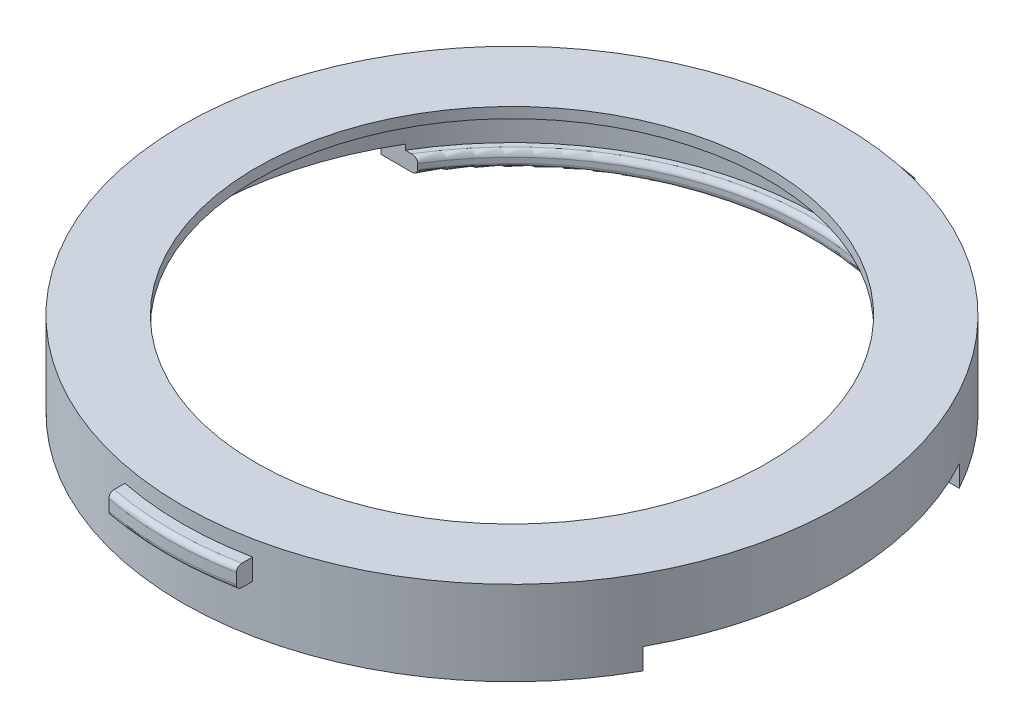
from build123d import *

# Parameters (mm, degrees)
SKETCH1_R                = 31.25
SKETCH1_R_2              = 29.25
BOSS_EXTRUDE2_DEPTH      = 8
SKETCH3_R                = 29.25
SKETCH3_R_2              = 28.25
BOSS_EXTRUDE3_DEPTH      = 1.5
FILLET1_R                = 0.5
SKETCH4_R                = 29.25
SKETCH4_R_2              = 24.25
BOSS_EXTRUDE4_DEPTH      = 1
CUT_EXTRUDE3_START       = 5
SKETCH5_W                = 70
SKETCH5_H                = 30
CUT_EXTRUDE3_DEPTH       = 2
BOSS_EXTRUDE5_DEPTH      = 1
BOSS_EXTRUDE5_DEPTH_BACK = 1
FILLET3_R                = 0.5


with BuildPart() as part:
    # Sketch1 → Boss-Extrude2 (new body)
    with BuildSketch(Plane(origin=(0, 0, 0), x_dir=(1, 0, 0), z_dir=(0, 1, 0))):
        Circle(SKETCH1_R)
        Circle(SKETCH1_R_2, mode=Mode.SUBTRACT)
    extrude(amount=BOSS_EXTRUDE2_DEPTH)

    # Sketch3 → Boss-Extrude3 (add)
    with BuildSketch(Plane(origin=(0, 1.5, 0), x_dir=(1, 0, 0), z_dir=(0, 1, 0))):
        Circle(SKETCH3_R)
        Circle(SKETCH3_R_2, mode=Mode.SUBTRACT)
    extrude(amount=-BOSS_EXTRUDE3_DEPTH)

    # Fillet1
    fillet1_edges = [part.edges().sort_by_distance(p)[0] for p in [
        (-28.25, 0, 0),
        (-28.25, 1.5, 0),
    ]]
    fillet(fillet1_edges, radius=FILLET1_R)

    # Sketch4 → Boss-Extrude4 (add)
    with BuildSketch(Plane(origin=(0, 8, 0), x_dir=(1, 0, 0), z_dir=(0, 1, 0))):
        Circle(SKETCH4_R)
        Circle(SKETCH4_R_2, mode=Mode.SUBTRACT)
    extrude(amount=-BOSS_EXTRUDE4_DEPTH)

    # Sketch5 → Cut-Extrude3 (cut)
    with BuildSketch(Plane.XZ.offset(-7).offset(CUT_EXTRUDE3_START)):
        Rectangle(SKETCH5_W, SKETCH5_H)
    extrude(amount=CUT_EXTRUDE3_DEPTH, mode=Mode.SUBTRACT)

    # Sketch6 → Boss-Extrude5 (add, two sides)
    with BuildSketch(Plane(origin=(0, 5.5, 0), x_dir=(1, 0, 0), z_dir=(0, 1, 0))) as boss_extrude5_sk:
        with BuildLine():
            Line((6.051043417, 30.658561179), (6.051043417, 32.186136357))
            ThreePointArc((6.051043417, 32.186136357), (0, 32.75), (-6.051043417, 32.186136357))
            Line((-6.051043417, 32.186136357), (-6.051043417, 30.658561179))
            ThreePointArc((-6.051043417, 30.658561179), (0, 31.25), (6.051043417, 30.658561179))
        make_face()
        with BuildLine():
            Line((-6.051043417, -32.186136357), (-6.051043417, -30.658561179))
            ThreePointArc((-6.051043417, -30.658561179), (0, -31.25), (6.051043417, -30.658561179))
            Line((6.051043417, -30.658561179), (6.051043417, -32.186136357))
            ThreePointArc((6.051043417, -32.186136357), (0, -32.75), (-6.051043417, -32.186136357))
        make_face()
    extrude(amount=BOSS_EXTRUDE5_DEPTH)
    extrude(boss_extrude5_sk.sketch, amount=-BOSS_EXTRUDE5_DEPTH_BACK)

    # Fillet3
    fillet3_edges = [part.edges().sort_by_distance(p)[0] for p in [
        (0, 4.5, -32.75),
        (0, 6.5, -32.75),
        (0, 4.5, 32.75),
        (0, 6.5, 32.75),
    ]]
    fillet(fillet3_edges, radius=FILLET3_R)


solid = part.part
